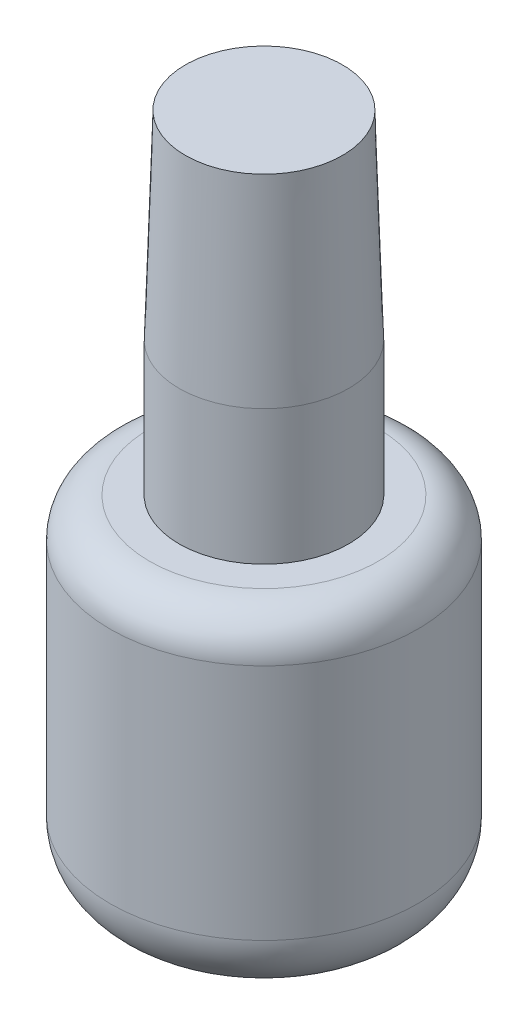
from build123d import *


with BuildPart() as part:
    # Sketch1 → Revolve1 (revolve)
    with BuildSketch(Plane.XY):
        with BuildLine():
            Line((12.446, 7.556707519), (12.446, 26.797))
            ThreePointArc((12.446, 26.797), (11.51606403, 29.04206403), (9.271, 29.972))
            Line((9.271, 29.972), (6.858, 29.972))
            Line((6.858, 29.972), (6.858, 40.8686))
            Line((6.858, 40.8686), (6.355531141, 56.9468))
            Line((6.355531141, 56.9468), (0, 56.9468))
            Line((0, 56.9468), (0, 0))
            ThreePointArc((0, 0), (5.504622181, 0.900649456), (10.435166667, 3.508668985))
            ThreePointArc((10.435166667, 3.508668985), (11.915602547, 5.296725955), (12.446, 7.556707519))
        make_face()
    revolve(axis=Axis((0, 56.9468, 0), (0, -1, 0)))


solid = part.part
